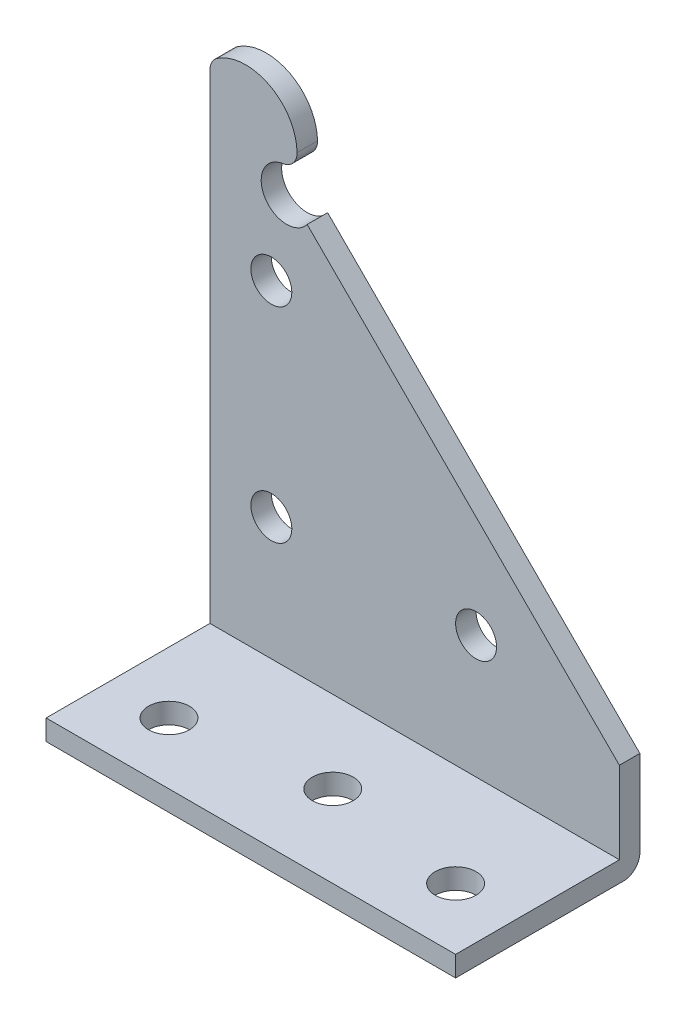
from build123d import *

# Parameters (mm, degrees)
SKETCH1_R           = 3.175
BOSS_EXTRUDE1_DEPTH = 3.175
SKETCH2_W           = 63.5
SKETCH2_H           = 25.4
SKETCH2_R           = 3.175
BOSS_EXTRUDE2_DEPTH = 3.175
FILLET1_R           = 2.54


with BuildPart() as part:
    # Sketch1 → Boss-Extrude1 (new body)
    with BuildSketch(Plane.XY):
        with BuildLine():
            Line((-41.275, 55.28710968), (-41.275, -22.225))
            Line((-41.275, -22.225), (22.225, -22.225))
            Line((22.225, -22.225), (22.225, -6.35))
            Line((22.225, -6.35), (-26.194658329, 42.069658329))
            ThreePointArc((-26.194658329, 42.069658329), (-32.769591892, 42.42721549), (-29.935488317, 48.370737627))
            ThreePointArc((-29.935488317, 48.370737627), (-28.368460583, 49.237906002), (-27.763159017, 50.923482141))
            ThreePointArc((-27.763159017, 50.923482141), (-32.032478959, 57.847259125), (-40.154061033, 57.393733943))
            ThreePointArc((-40.154061033, 57.393733943), (-40.977321902, 56.480253631), (-41.275, 55.28710968))
        make_face()
        Circle(SKETCH1_R, mode=Mode.SUBTRACT)
        with Locations((-31.75, 0)):
            Circle(SKETCH1_R, mode=Mode.SUBTRACT)
        with Locations((-31.75, 31.75)):
            Circle(SKETCH1_R, mode=Mode.SUBTRACT)
    extrude(amount=BOSS_EXTRUDE1_DEPTH)

    # Sketch2 → Boss-Extrude2 (add)
    with BuildSketch(Plane(origin=(0, -22.225, 0), x_dir=(1, 0, 0), z_dir=(0, 1, 0))):
        with Locations((-9.525, -15.875)):
            Rectangle(SKETCH2_W, SKETCH2_H)
        with Locations((-9.525, -15.875)):
            Circle(SKETCH2_R, mode=Mode.SUBTRACT)
        with Locations((-31.75, -19.05)):
            Circle(SKETCH2_R, mode=Mode.SUBTRACT)
        with Locations((12.7, -19.05)):
            Circle(SKETCH2_R, mode=Mode.SUBTRACT)
    extrude(amount=BOSS_EXTRUDE2_DEPTH)

    # Fillet1
    fillet1_edges = [part.edges().sort_by_distance(p)[0] for p in [
        (-9.525, -22.225, 0),
    ]]
    fillet(fillet1_edges, radius=FILLET1_R)


solid = part.part
